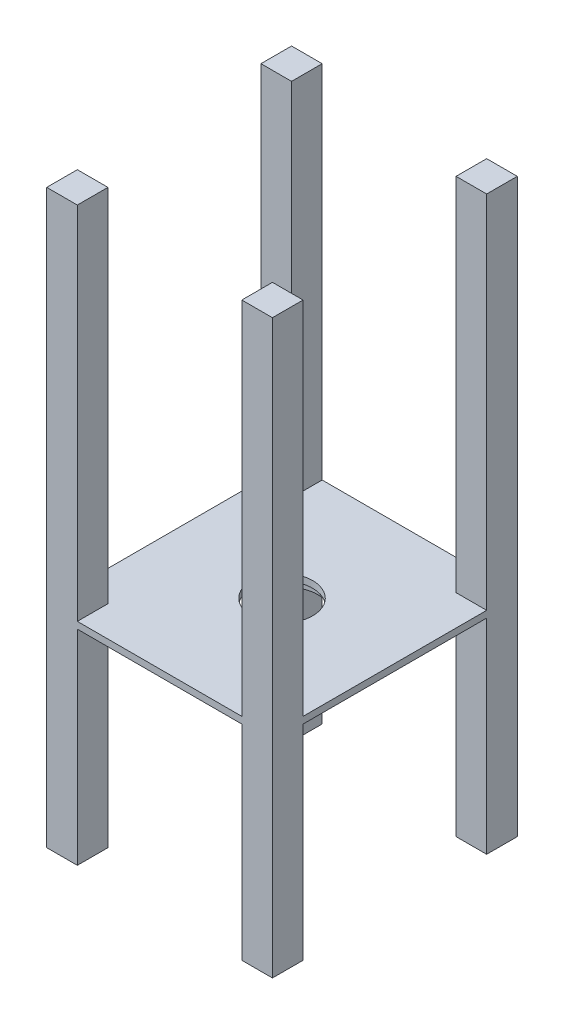
from build123d import *

# Parameters (mm, degrees)
BOSS_EXTRUDE2_DEPTH  = 11.1125
SKETCH1_11_W         = 50.8
SKETCH1_11_H         = 50.8
BOSS_EXTRUDE3_DEPTH  = 609.6
SKETCH1_12_W         = 50.8
SKETCH1_12_H         = 50.8
BOSS_EXTRUDE4_DEPTH  = 609.6
SKETCH1_13_W         = 50.8
SKETCH1_13_H         = 50.8
BOSS_EXTRUDE5_DEPTH  = 609.6
SKETCH1_14_W         = 50.8
SKETCH1_14_H         = 50.8
BOSS_EXTRUDE6_DEPTH  = 609.6
SKETCH4_R            = 50.8
CUT_EXTRUDE2_DEPTH   = 12.1125
SKETCH5_W            = 165.1
SKETCH5_H            = 152.4
SKETCH5_W_2          = 139.7
SKETCH5_H_2          = 127
BOSS_EXTRUDE8_DEPTH  = 17.78
SKETCH13_W           = 50.8
SKETCH13_H           = 50.8
BOSS_EXTRUDE13_DEPTH = 339.6
SKETCH15_R           = 69.931982246
SKETCH15_R_2         = 63.5
BOSS_EXTRUDE14_DEPTH = 17


with BuildPart() as part:
    # Sketch1 → Boss-Extrude2 (new body)
    with BuildSketch(Plane(origin=(0, 0, 0), x_dir=(1, 0, 0), z_dir=(0, 1, 0))):
        Polygon((-136.525, 152.4), (-187.325, 152.4), (-187.325, -203.2), (187.325, -203.2), (187.325, 203.2), (-136.525, 203.2), align=None)
    extrude(amount=BOSS_EXTRUDE2_DEPTH)

    # Sketch1_11 → Boss-Extrude3 (add)
    with BuildSketch(Plane(origin=(0, 0, 0), x_dir=(1, 0, 0), z_dir=(0, 1, 0))):
        with Locations((-161.925, 177.8)):
            Rectangle(SKETCH1_11_W, SKETCH1_11_H)
    extrude(amount=BOSS_EXTRUDE3_DEPTH)

    # Sketch1_12 → Boss-Extrude4 (add)
    with BuildSketch(Plane(origin=(0, 0, 0), x_dir=(1, 0, 0), z_dir=(0, 1, 0))):
        with Locations((-161.925, -177.8)):
            Rectangle(SKETCH1_12_W, SKETCH1_12_H)
    extrude(amount=BOSS_EXTRUDE4_DEPTH)

    # Sketch1_13 → Boss-Extrude5 (add)
    with BuildSketch(Plane(origin=(0, 0, 0), x_dir=(1, 0, 0), z_dir=(0, 1, 0))):
        with Locations((161.925, 177.8)):
            Rectangle(SKETCH1_13_W, SKETCH1_13_H)
    extrude(amount=BOSS_EXTRUDE5_DEPTH)

    # Sketch1_14 → Boss-Extrude6 (add)
    with BuildSketch(Plane(origin=(0, 0, 0), x_dir=(1, 0, 0), z_dir=(0, 1, 0))):
        with Locations((161.925, -177.8)):
            Rectangle(SKETCH1_14_W, SKETCH1_14_H)
    extrude(amount=BOSS_EXTRUDE6_DEPTH)

    # Sketch4 → Cut-Extrude2 (cut, through all)
    with BuildSketch(Plane(origin=(0, 11.1125, 0), x_dir=(1, 0, 0), z_dir=(0, 1, 0))):
        Circle(SKETCH4_R)
    extrude(amount=-CUT_EXTRUDE2_DEPTH, mode=Mode.SUBTRACT)

    # Sketch5 → Boss-Extrude8 (add)
    with BuildSketch(Plane.XZ):
        Rectangle(SKETCH5_W, SKETCH5_H)
        Rectangle(SKETCH5_W_2, SKETCH5_H_2, mode=Mode.SUBTRACT)
    extrude(amount=BOSS_EXTRUDE8_DEPTH)

    # Sketch13 → Boss-Extrude13 (add)
    with BuildSketch(Plane.XZ):
        with Locations((-161.925, 177.8)):
            Rectangle(SKETCH13_W, SKETCH13_H)
        with Locations((161.925, 177.8)):
            Rectangle(SKETCH13_W, SKETCH13_H)
        with Locations((161.925, -177.8)):
            Rectangle(SKETCH13_W, SKETCH13_H)
        with Locations((-161.925, -177.8)):
            Rectangle(SKETCH13_W, SKETCH13_H)
    extrude(amount=BOSS_EXTRUDE13_DEPTH)

    # Sketch15 → Boss-Extrude14 (add)
    with BuildSketch(Plane.XZ):
        Circle(SKETCH15_R)
        Circle(SKETCH15_R_2, mode=Mode.SUBTRACT)
    extrude(amount=BOSS_EXTRUDE14_DEPTH)


solid = part.part
